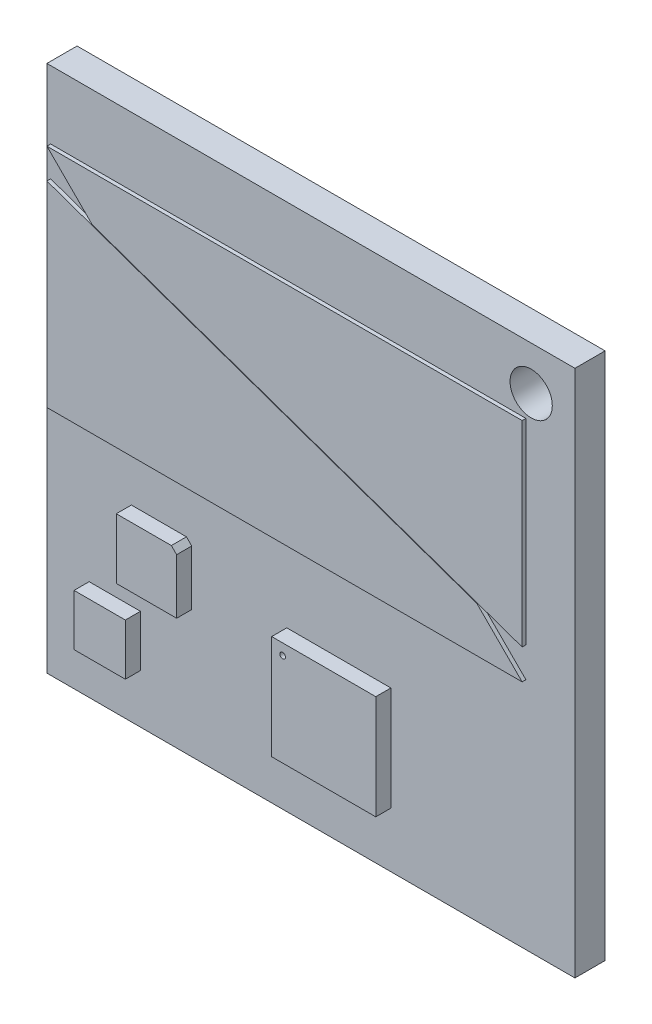
from build123d import *

# Parameters (mm, degrees)
MODEL_W             = 35
MODEL_H             = 35
BOSS_EXTRUDE1_DEPTH = 2
MODEL_3_R           = 1.4
CUT_EXTRUDE1_DEPTH  = 50.537864306
MODEL_4_W           = 6.9
MODEL_4_H           = 6.9
MODEL_4_R           = 0.1855
BOSS_EXTRUDE2_DEPTH = 1
BOSS_EXTRUDE3_DEPTH = 0.25


with BuildPart() as part:
    # Model → Boss-Extrude1 (new body)
    with BuildSketch(Plane.XY):
        with Locations((17.5, 17.5)):
            Rectangle(MODEL_W, MODEL_H)
    extrude(amount=-BOSS_EXTRUDE1_DEPTH)

    # Model_3 → Cut-Extrude1 (cut, through all)
    with BuildSketch(Plane.XY):
        with Locations((32.1, 32.1)):
            Circle(MODEL_3_R)
    extrude(amount=-CUT_EXTRUDE1_DEPTH, mode=Mode.SUBTRACT)

    # Model_4 → Boss-Extrude2 (add)
    # profile 1 of 3: a face of its own
    with BuildSketch(Plane.XY):
        with Locations((19.35, 7.1)):
            Rectangle(MODEL_4_W, MODEL_4_H)
        with Locations((16.63, 9.82)):
            Circle(MODEL_4_R, mode=Mode.SUBTRACT)
    # profile 2 of 3: a face of its own
    with BuildSketch(Plane.XY):
        Polygon((3.4508, 6.65), (2.8, 6.65), (2.8, 5.9992), (2.8, 3.9008), (2.8, 3.25), (3.4508, 3.25), (5.5492, 3.25), (6.2, 3.25), (6.2, 3.9008), (6.2, 6.65), align=None)
    # profile 3 of 3: a face of its own
    with BuildSketch(Plane.XY):
        Polygon((5.6, 8.8508), (5.6, 8.45), (6.0008, 8.45), (9.1992, 8.45), (9.6, 8.45), (9.6, 8.8508), (9.6, 12.049229733), (9.6, 12.1), (9.25, 12.45), (9.199229733, 12.45), (6.0008, 12.45), (5.6, 12.45), (5.6, 12.0492), align=None)
    extrude(amount=BOSS_EXTRUDE2_DEPTH)

    # Model_5 → Boss-Extrude3 (add)
    with BuildSketch(Plane.XY):
        Polygon((0.25, 28.5), (0.25, 15.5), (31.75, 15.5), (28.772474986, 18.477525014), (28.75, 18.5), (28.719974832, 18.510535147), align=None)
        Polygon((31.75, 30.5), (0.25, 30.5), (3.227525014, 27.522474986), (3.25, 27.5), (3.280025168, 27.489464853), (31.75, 17.5), align=None)
    extrude(amount=BOSS_EXTRUDE3_DEPTH)


solid = part.part
